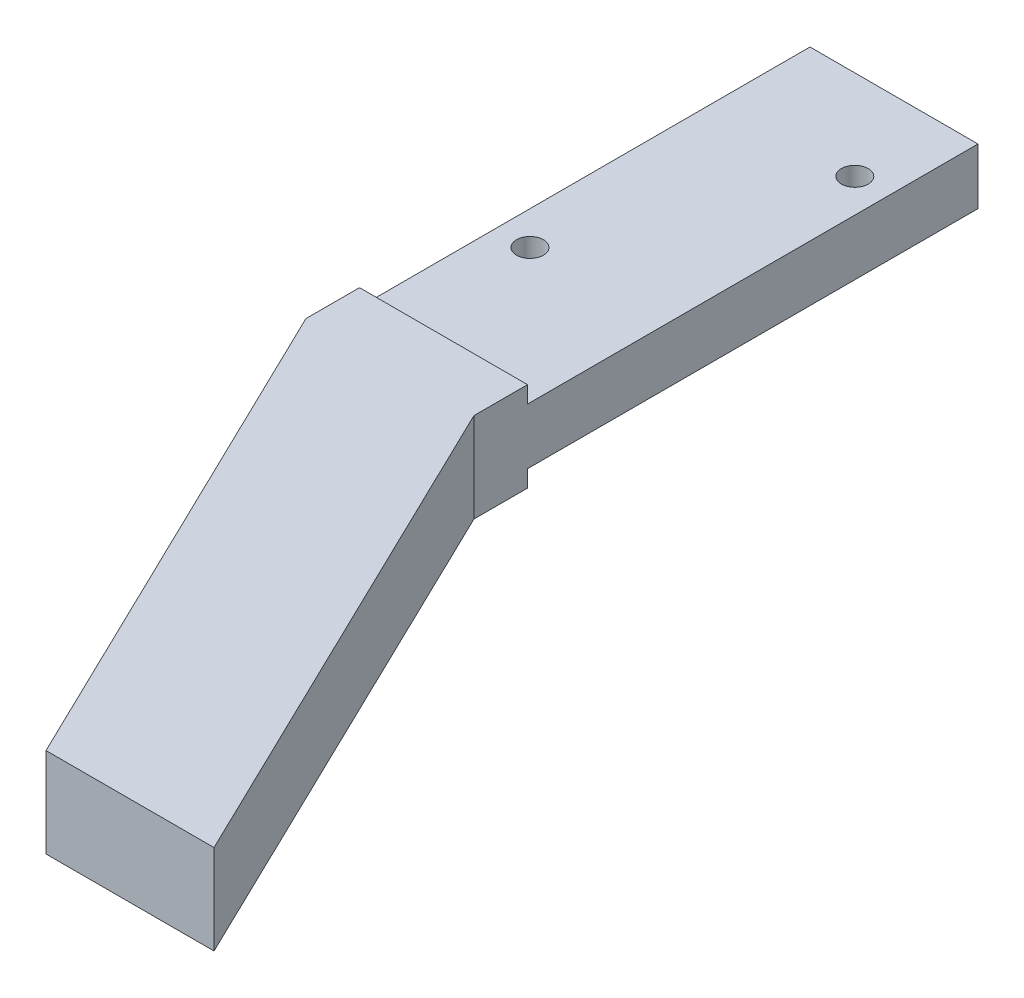
from build123d import *

# Parameters (mm, degrees)
SKETCH1_W           = 15
SKETCH1_H           = 45
SKETCH1_R           = 1.2
BOSS_EXTRUDE1_DEPTH = 2.5
BOSS_EXTRUDE2_DEPTH = 4


with BuildPart() as part:
    # Sketch1 → Boss-Extrude1 (new body, symmetric)
    with BuildSketch(Plane(origin=(0, 0, 0), x_dir=(1, 0, 0), z_dir=(0, 1, 0))):
        Rectangle(SKETCH1_W, SKETCH1_H)
        with Locations((-4.5, -5.5)):
            Circle(SKETCH1_R, mode=Mode.SUBTRACT)
        with Locations((4.5, 14.5)):
            Circle(SKETCH1_R, mode=Mode.SUBTRACT)
    extrude(amount=BOSS_EXTRUDE1_DEPTH, both=True)

    # Sketch4 → Boss-Extrude2 (add, symmetric)
    with BuildSketch(Plane(origin=(0, 0, 0), x_dir=(1, 0, 0), z_dir=(0, 1, 0))):
        Polygon((-7.5, -17.715662228), (-7.5, -22.5), (14.294494718, -67.5), (29.294494718, -67.5), (7.5, -22.5), (7.5, -17.715662228), align=None)
    extrude(amount=BOSS_EXTRUDE2_DEPTH, both=True)


solid = part.part
